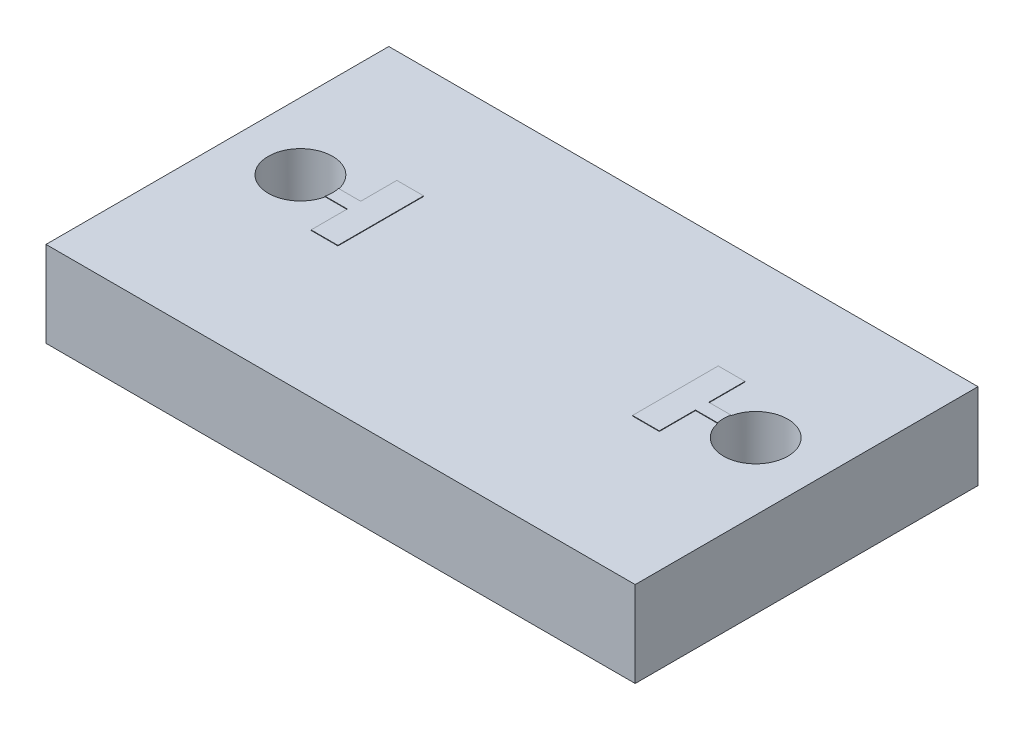
from build123d import *

# Parameters (mm, degrees)
SKETCH1_W           = 11
SKETCH1_H           = 4
BOSS_EXTRUDE1_DEPTH = 1.6
SKETCH3_R           = 0.6
CUT_EXTRUDE1_DEPTH  = 1.6
SKETCH2_W           = 0.5
SKETCH2_H           = 1.6
BOSS_EXTRUDE2_DEPTH = 0.01
BOSS_EXTRUDE3_DEPTH = 0.01
SKETCH5_W           = 11
SKETCH5_H           = 1.6
BOSS_EXTRUDE4_DEPTH = 1.5
SKETCH6_W           = 11
SKETCH6_H           = 1.6
BOSS_EXTRUDE5_DEPTH = 0.9


with BuildPart() as part:
    # Sketch1 → Boss-Extrude1 (new body)
    with BuildSketch(Plane(origin=(0, 0, 0), x_dir=(1, 0, 0), z_dir=(0, 1, 0))):
        Rectangle(SKETCH1_W, SKETCH1_H)
    extrude(amount=BOSS_EXTRUDE1_DEPTH)

    # Sketch3 → Cut-Extrude1 (cut)
    with BuildSketch(Plane(origin=(0, 1.6, 0), x_dir=(1, 0, 0), z_dir=(0, 1, 0))):
        with Locations((4.25, 0)):
            Circle(SKETCH3_R)
        with Locations((-4.25, 0)):
            Circle(SKETCH3_R)
    extrude(amount=-CUT_EXTRUDE1_DEPTH, mode=Mode.SUBTRACT)

    # Sketch2 → Boss-Extrude2 (add)
    with BuildSketch(Plane(origin=(0, 1.6, 0), x_dir=(1, 0, 0), z_dir=(0, 1, 0))):
        with Locations((-3, 0)):
            Rectangle(SKETCH2_W, SKETCH2_H)
        with Locations((3, 0)):
            Rectangle(SKETCH2_W, SKETCH2_H)
    extrude(amount=BOSS_EXTRUDE2_DEPTH)

    # Sketch4 → Boss-Extrude3 (add)
    with BuildSketch(Plane(origin=(0, 1.6, 0), x_dir=(1, 0, 0), z_dir=(0, 1, 0))):
        with BuildLine():
            Line((3.25, -0.125), (3.663165, -0.125))
            ThreePointArc((3.663165, -0.125), (3.65, 0), (3.663165, 0.125))
            Line((3.663165, 0.125), (3.25, 0.125))
            Line((3.25, 0.125), (3.25, -0.125))
        make_face()
        with BuildLine():
            Line((-3.25, 0.125), (-3.663165, 0.125))
            ThreePointArc((-3.663165, 0.125), (-3.6533, 0.062846), (-3.65, 0))
            ThreePointArc((-3.65, 0), (-3.6533, -0.062846), (-3.663165, -0.125))
            Line((-3.663165, -0.125), (-3.25, -0.125))
            Line((-3.25, -0.125), (-3.25, 0.125))
        make_face()
    extrude(amount=BOSS_EXTRUDE3_DEPTH)

    # Sketch5 → Boss-Extrude4 (add)
    with BuildSketch(Plane.XY.offset(2)):
        with Locations((0, 0.8)):
            Rectangle(SKETCH5_W, SKETCH5_H)
    extrude(amount=BOSS_EXTRUDE4_DEPTH)

    # Sketch6 → Boss-Extrude5 (add)
    with BuildSketch(Plane(origin=(0, 0, -2), x_dir=(-1, 0, 0), z_dir=(0, 0, -1))):
        with Locations((0, 0.8)):
            Rectangle(SKETCH6_W, SKETCH6_H)
    extrude(amount=BOSS_EXTRUDE5_DEPTH)


solid = part.part
